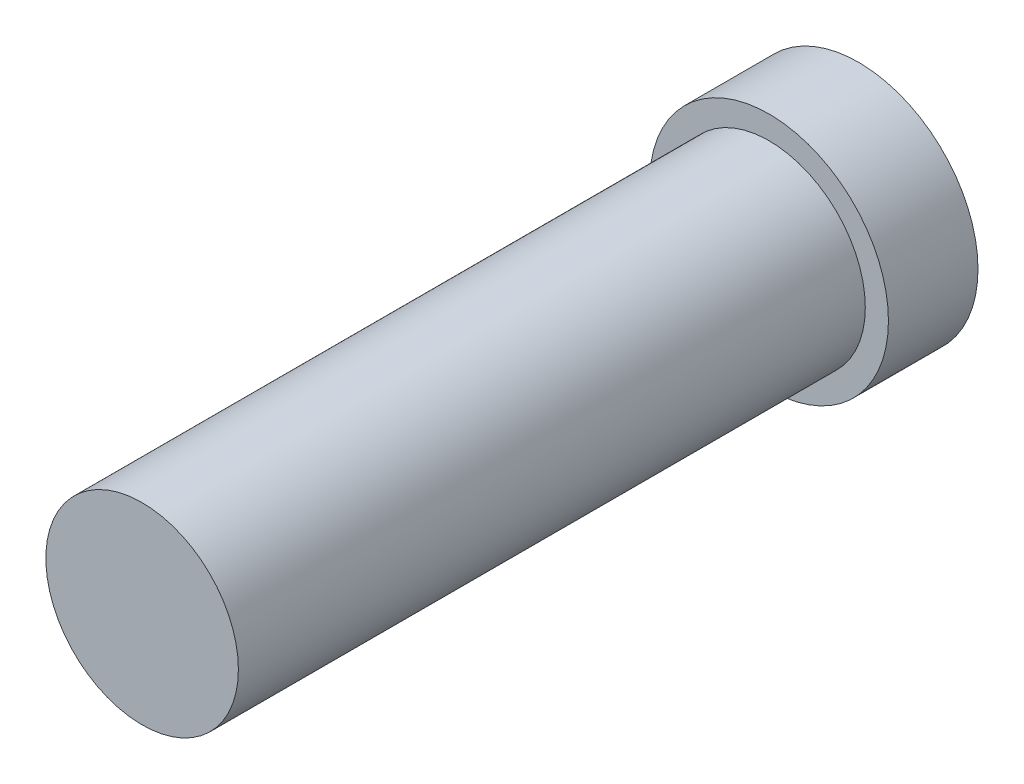
from build123d import *

# Parameters (mm, degrees)
SKETCH1_R           = 3.225
BOSS_EXTRUDE1_DEPTH = 21
SKETCH2_R           = 4
BOSS_EXTRUDE2_DEPTH = 3


with BuildPart() as part:
    # Sketch1 → Boss-Extrude1 (new body)
    with BuildSketch(Plane.XY):
        Circle(SKETCH1_R)
    extrude(amount=BOSS_EXTRUDE1_DEPTH)

    # Sketch2 → Boss-Extrude2 (add)
    with BuildSketch(Plane.XY):
        Circle(SKETCH2_R)
    extrude(amount=-BOSS_EXTRUDE2_DEPTH)


solid = part.part
